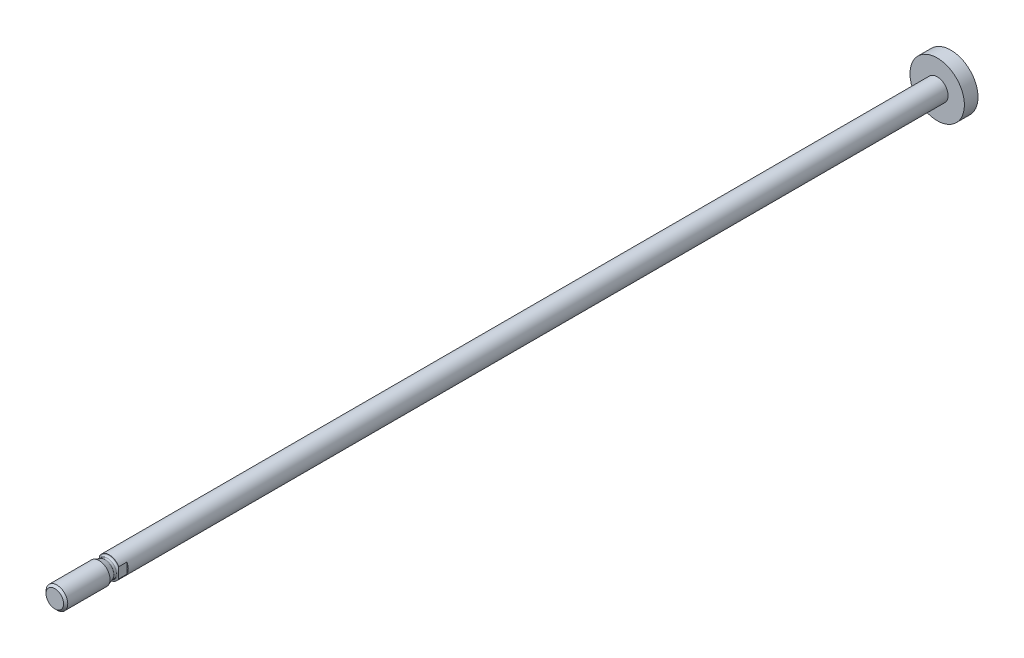
from build123d import *

# Parameters (mm, degrees)
CUT_EXTRUDE1_DEPTH = 4


with BuildPart() as part:
    # Sketch1 → Revolve1 (revolve)
    with BuildSketch(Plane(origin=(0, 0, 0), x_dir=(0, 0, -1), z_dir=(1, 0, 0))):
        Polygon((-4, 0), (-4, 4), (300.3, 4), (300.3, 10), (305.3, 10), (305.3, 0), align=None)
    revolve(axis=Axis((0, 0, -305.3), (0, 0, 1)))

    # Sketch2 → Revolve2 (revolve)
    with BuildSketch(Plane(origin=(0, 0, 0), x_dir=(0, 0, -1), z_dir=(1, 0, 0))):
        with BuildLine():
            Line((-24, 0), (-24, 3.233))
            Line((-24, 3.233), (-23.233, 4))
            Line((-23.233, 4), (-7.697981936, 4))
            Line((-7.697981936, 4), (-5.599415898, 3.236184428))
            ThreePointArc((-5.599415898, 3.236184428), (-5.498392718, 3.209115348), (-5.394203812, 3.2))
            Line((-5.394203812, 3.2), (-4.6, 3.2))
            ThreePointArc((-4.6, 3.2), (-4.175735931, 3.375735931), (-4, 3.8))
            Line((-4, 3.8), (-4, 4))
            Line((-4, 4), (-3, 4))
            Line((-3, 4), (-3, 0))
            Line((-3, 0), (-24, 0))
        make_face()
    revolve(axis=Axis((0, 0, 3), (0, 0, 1)))

    # Sketch3 → Cut-Extrude1 (cut)
    with BuildSketch(Plane.XY.offset(1)):
        Polygon((-7, 14), (-7, -7), (-3.5, -7), (-3.5, 7), (3.5, 7), (3.5, -7), (7, -7), (7, 14), align=None)
    extrude(amount=CUT_EXTRUDE1_DEPTH, mode=Mode.SUBTRACT)


solid = part.part
